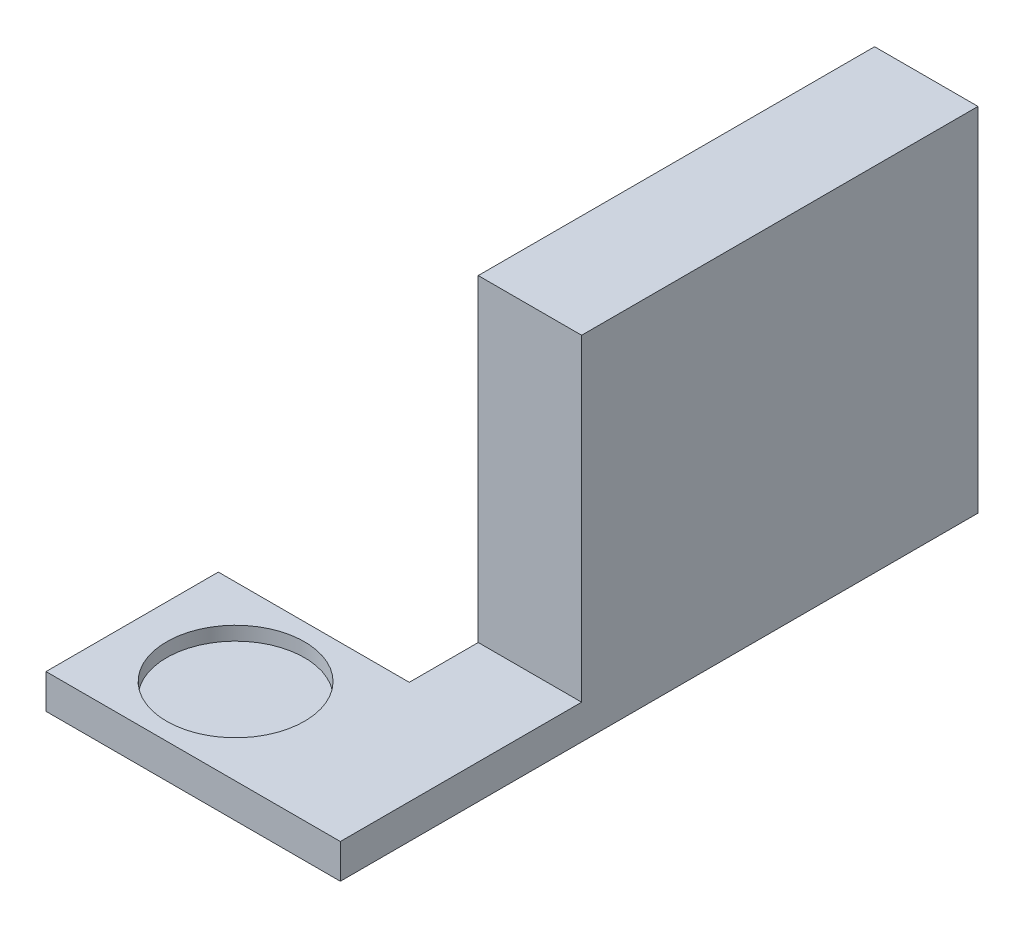
from build123d import *

# Parameters (mm, degrees)
SKETCH1_W           = 100
SKETCH1_H           = 40
BOSS_EXTRUDE1_DEPTH = 15
MOVE_FACE4_BY       = 5
SKETCH5_R           = 10
CUT_EXTRUDE2_DEPTH  = 2
MOVE_FACE5_BY       = 7.5
MOVE_FACE5_2_BY     = 7.5
MOVE_FACE7_BY       = 75
MOVE_FACE8_BY       = 5
MOVE_FACE9_BY       = 12.7
SKETCH6_W           = 15
SKETCH6_H           = 10
BOSS_EXTRUDE2_DEPTH = 100
MOVE_FACE10_BY      = 22.5
SKETCH7_W           = 15
SKETCH7_H           = 77.5
BOSS_EXTRUDE3_DEPTH = 47.8
MOVE_FACE11_BY      = 5
MOVE_FACE12_BY      = 6.7
MOVE_FACE13_BY      = 4.1
MOVE_FACE16_BY      = 0.9
MOVE_FACE17_BY      = 10
MOVE_FACE18_BY      = 10


with BuildPart() as part:
    # Sketch1 → Boss-Extrude1 (new body)
    with BuildSketch(Plane(origin=(0, 0, 0), x_dir=(1, 0, 0), z_dir=(0, 1, 0))):
        Rectangle(SKETCH1_W, SKETCH1_H)
    extrude(amount=BOSS_EXTRUDE1_DEPTH)

    # Move Face4: a face moved outward by 5.0
    extrude(part.faces().sort_by_distance((50, 7.5, 0))[0], amount=MOVE_FACE4_BY, dir=(1, 0, 0))

    # Sketch5 → Cut-Extrude2 (cut)
    with BuildSketch(Plane(origin=(0, 15, 0), x_dir=(1, 0, 0), z_dir=(0, 1, 0))):
        with Locations(Location((40, 0, 0), (0, 0, 270))):
            Circle(SKETCH5_R)
    extrude(amount=-CUT_EXTRUDE2_DEPTH, mode=Mode.SUBTRACT)

    # Move Face5: a face moved inward by 7.5
    extrude(part.faces().sort_by_distance((2.5, 7.5, -20))[0], amount=MOVE_FACE5_BY, dir=(0, 0, 1), mode=Mode.SUBTRACT)

    # Move Face5 2: a face moved inward by 7.5
    extrude(part.faces().sort_by_distance((2.5, 7.5, 20))[0], amount=MOVE_FACE5_2_BY, dir=(0, 0, -1), mode=Mode.SUBTRACT)

    # Move Face7: a face moved inward by 75.0
    extrude(part.faces().sort_by_distance((-50, 7.5, 0))[0], amount=MOVE_FACE7_BY, dir=(1, 0, 0), mode=Mode.SUBTRACT)

    # Move Face8: a face moved inward by 5.0
    extrude(part.faces().sort_by_distance((40, 0, 0))[0], amount=MOVE_FACE8_BY, dir=(0, 1, 0), mode=Mode.SUBTRACT)

    # Move Face9: a face moved outward by 12.7
    extrude(part.faces().sort_by_distance((55, 10, 0))[0], amount=MOVE_FACE9_BY, dir=(1, 0, 0))

    # Sketch6 → Boss-Extrude2 (add)
    with BuildSketch(Plane(origin=(0, 0, -12.5), x_dir=(-1, 0, 0), z_dir=(0, 0, -1))):
        with Locations((-60.2, 10)):
            Rectangle(SKETCH6_W, SKETCH6_H)
    extrude(amount=BOSS_EXTRUDE2_DEPTH)

    # Move Face10: a face moved inward by 22.5
    extrude(part.faces().sort_by_distance((60.2, 10, -112.5))[0], amount=MOVE_FACE10_BY, dir=(0, 0, 1), mode=Mode.SUBTRACT)

    # Sketch7 → Boss-Extrude3 (add)
    with BuildSketch(Plane(origin=(0, 15, 0), x_dir=(1, 0, 0), z_dir=(0, 1, 0))):
        with Locations((60.2, 51.25)):
            Rectangle(SKETCH7_W, SKETCH7_H)
    extrude(amount=BOSS_EXTRUDE3_DEPTH)

    # Move Face11: a face moved inward by 5.0
    extrude(part.faces().sort_by_distance((53.570011211, 5, -26.716647982))[0], amount=MOVE_FACE11_BY, dir=(0, 1, 0), mode=Mode.SUBTRACT)

    # Move Face12: a face moved inward by 6.7
    extrude(part.faces().sort_by_distance((60.2, 62.8, -51.25))[0], amount=MOVE_FACE12_BY, dir=(0, -1, 0), mode=Mode.SUBTRACT)

    # Move Face13: a face moved outward by 4.1
    extrude(part.faces().sort_by_distance((60.2, 56.1, -51.25))[0], amount=MOVE_FACE13_BY, dir=(0, 1, 0))

    # Move Face16: a face moved outward by 0.9
    extrude(part.faces().sort_by_distance((60.2, 60.2, -51.25))[0], amount=MOVE_FACE16_BY, dir=(0, 1, 0))

    # Move Face17: a face moved inward by 10.0
    extrude(part.faces().sort_by_distance((60.2, 38.05, -12.5))[0], amount=MOVE_FACE17_BY, dir=(0, 0, -1), mode=Mode.SUBTRACT)

    # Move Face18: a face moved inward by 10.0
    extrude(part.faces().sort_by_distance((60.2, 35.55, -90))[0], amount=MOVE_FACE18_BY, dir=(0, 0, 1), mode=Mode.SUBTRACT)


solid = part.part
